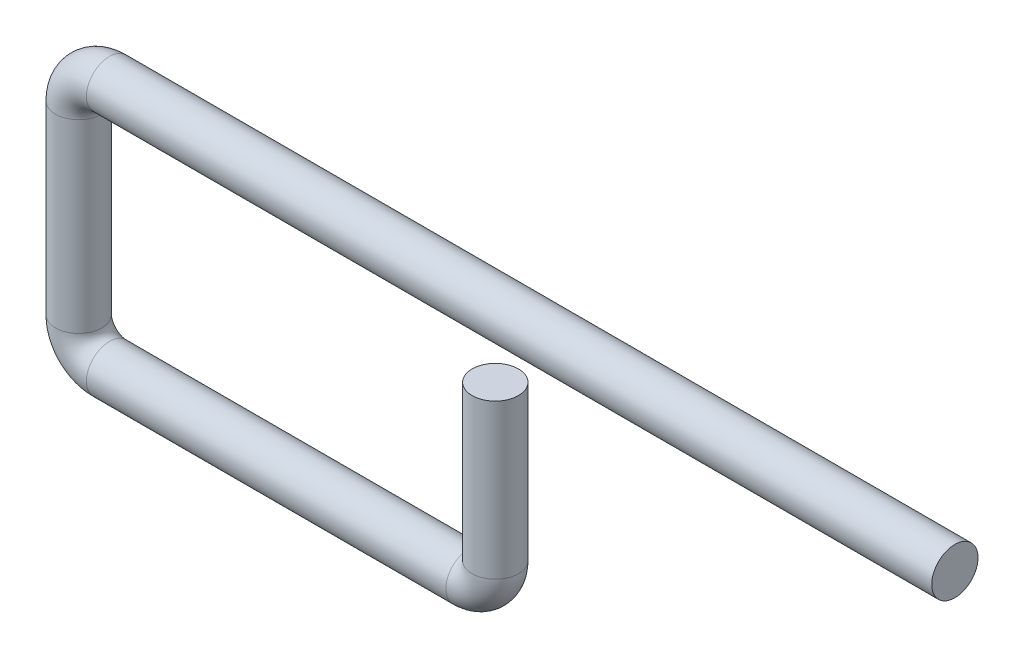
from build123d import *

# Parameters (mm, degrees)
SKETCH2_R = 3.75


with BuildPart() as part:
    # Sweep1: sweep along a path in Sketch1
    with BuildLine(Plane.XY) as sweep1_path:
        Line((0, 0), (-137, 0))
        ThreePointArc((-137, 0), (-140.535533906, -1.464466094), (-142, -5))
        Line((-142, -5), (-142, -35))
        ThreePointArc((-142, -35), (-140.535533906, -38.535533906), (-137, -40))
        Line((-137, -40), (-78.75, -40))
        ThreePointArc((-78.75, -40), (-75.732099511, -38.749944688), (-74.482044199, -35.732044199))
        Line((-74.482044199, -35.732044199), (-74.482044199, -10.732044199))
    # Sketch2 → Sweep1 (sweep)
    with BuildSketch(Plane(origin=(0, 0, 0), x_dir=(0, 0, -1), z_dir=(1, 0, 0))):
        Circle(SKETCH2_R)
    sweep(path=sweep1_path.line)


solid = part.part
